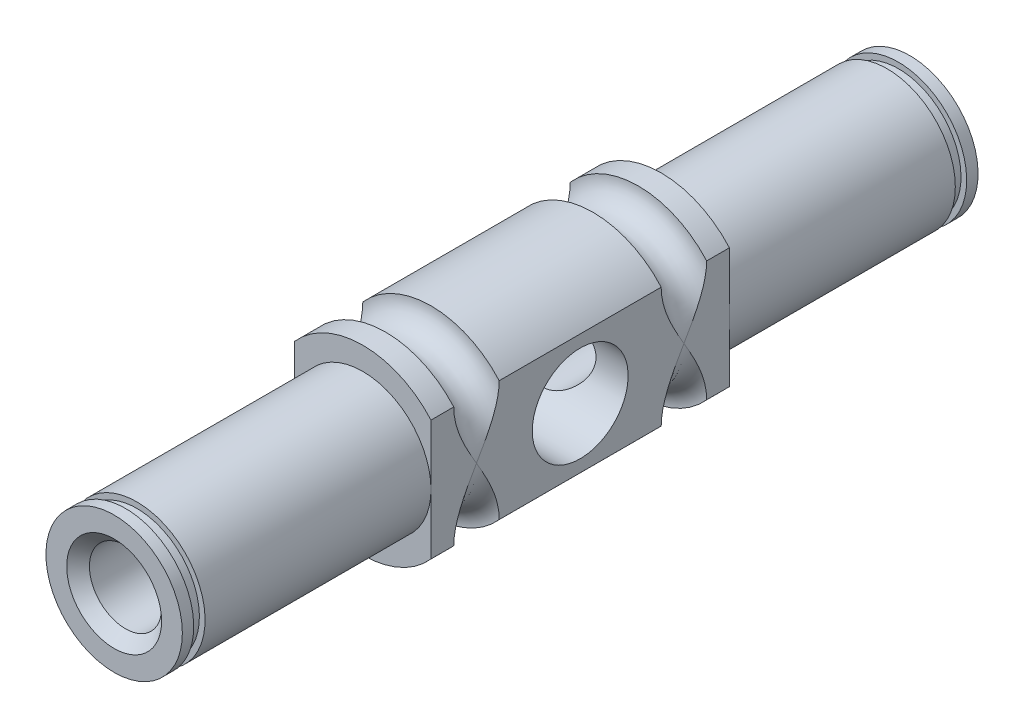
from build123d import *

# Parameters (mm, degrees)
SKETCH1_R               = 8
BOSS_EXTRUDE1_DEPTH     = 26.25
SKETCH2_R               = 6
BOSS_EXTRUDE2_DEPTH     = 21.875
BOSS_EXTRUDE3_START     = 21.875
SKETCH3_R               = 6
BOSS_EXTRUDE3_DEPTH     = 21.875
CUT_EXTRUDE4_DEPTH      = 50.436986407
CUT_EXTRUDE4_DEPTH_BACK = 50.436986407
SKETCH7_W               = 1
SKETCH7_H               = 0.5
SKETCH9_R               = 3.175
CUT_EXTRUDE5_DEPTH      = 71.710678138
CHAMFER1_SIZE           = 1
F_3_8_24_TAPPED_HOLE1_D = 8.4328


with BuildPart() as part:
    # Sketch1 → Boss-Extrude1 (new body)
    with BuildSketch(Plane.XY):
        Circle(SKETCH1_R)
    extrude(amount=BOSS_EXTRUDE1_DEPTH)

    # Sketch2 → Boss-Extrude2 (add)
    with BuildSketch(Plane(origin=(0, 0, 0), x_dir=(-1, 0, 0), z_dir=(0, 0, -1))):
        Circle(SKETCH2_R)
    extrude(amount=BOSS_EXTRUDE2_DEPTH)

    # Sketch3 → Boss-Extrude3 (add)
    with BuildSketch(Plane.XY.offset(26.25).offset(BOSS_EXTRUDE3_START)):
        Circle(SKETCH3_R)
    extrude(amount=-BOSS_EXTRUDE3_DEPTH)

    # Sketch5 → Cut-Extrude4 (cut, two sides: drawn at the far end of the back side and taken through both)
    with BuildSketch(Plane(origin=(0, 0, 0), x_dir=(-1, 0, 0), z_dir=(0, 0, -1)).offset(-CUT_EXTRUDE4_DEPTH_BACK)):
        with BuildLine():
            Line((-6, -5.291502622), (-6, 5.291502622))
            ThreePointArc((-6, 5.291502622), (-8, 0), (-6, -5.291502622))
        make_face()
        with BuildLine():
            ThreePointArc((6, -5.291502622), (8, 0), (6, 5.291502622))
            Line((6, 5.291502622), (6, -5.291502622))
        make_face()
    extrude(amount=CUT_EXTRUDE4_DEPTH + CUT_EXTRUDE4_DEPTH_BACK, mode=Mode.SUBTRACT)

    # Sketch7 → Cut-Revolve1 (revolve, cut)
    with BuildSketch(Plane(origin=(0, 0, 0), x_dir=(0, 0, -1), z_dir=(1, 0, 0))):
        with Locations((20.375, 5.75)):
            Rectangle(SKETCH7_W, SKETCH7_H)
        with Locations((-46.625, 5.75)):
            Rectangle(SKETCH7_W, SKETCH7_H)
    revolve(axis=Axis((0, 0, 48.125), (0, 0, -1)), mode=Mode.SUBTRACT)

    # Sketch8 → Cut-Revolve2 (revolve, cut)
    with BuildSketch(Plane(origin=(0, 0, 0), x_dir=(0, 0, -1), z_dir=(1, 0, 0))):
        with BuildLine():
            Line((-24.25, 8), (-20.25, 8))
            ThreePointArc((-20.25, 8), (-22.25, 6), (-24.25, 8))
        make_face()
        with BuildLine():
            Line((-6, 8), (-2, 8))
            ThreePointArc((-2, 8), (-4, 6), (-6, 8))
        make_face()
    revolve(axis=Axis((0, 0, 48.125), (0, 0, -1)), mode=Mode.SUBTRACT)

    # Sketch9 → Cut-Extrude5 (cut, through all)
    with BuildSketch(Plane.XY.offset(48.125)):
        Circle(SKETCH9_R)
    extrude(amount=-CUT_EXTRUDE5_DEPTH, mode=Mode.SUBTRACT)

    # Chamfer1
    chamfer1_edges = [part.edges().sort_by_distance(p)[0] for p in [
        (-3.175, 0, -21.875),
        (-3.175, 0, 48.125),
    ]]
    chamfer(chamfer1_edges, length=CHAMFER1_SIZE)

    # 3_8-24 Tapped Hole1 (through all)
    with Locations(Plane.ZY.offset(6)):
        with Locations((13.125, 0)):
            Hole(F_3_8_24_TAPPED_HOLE1_D / 2)


solid = part.part
